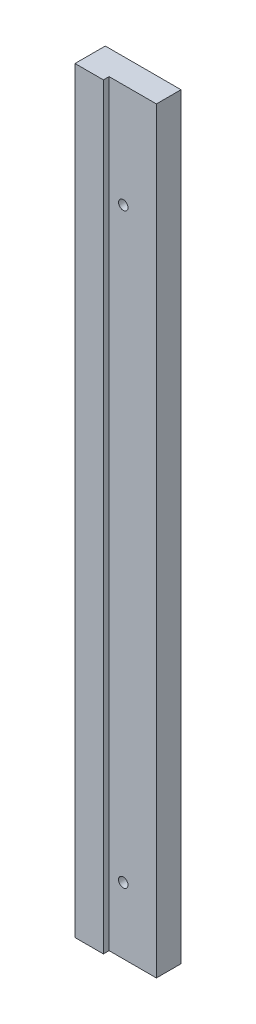
from build123d import *

# Parameters (mm, degrees)
SKETCH1_W         = 40
SKETCH1_H         = 400
EXTRUDE1_DEPTH    = 16
EXTRUDE2_REACH    = 402
SKETCH2_W         = 25
SKETCH2_H         = 3
M6_TAPPED_HOLE1_D = 5


with BuildPart() as part:
    # Sketch1 → Extrude1 (new body)
    with BuildSketch(Plane.XY):
        Rectangle(SKETCH1_W, SKETCH1_H)
    extrude(amount=EXTRUDE1_DEPTH)

    # Sketch2 → Extrude2 (cut, up to next)
    with BuildSketch(Plane.XZ.offset(200), mode=Mode.PRIVATE) as extrude2_sk1:
        with Locations((7.5, 14.5)):
            Rectangle(SKETCH2_W, SKETCH2_H)
    extrude2_tool1 = extrude(extrude2_sk1.sketch, amount=-EXTRUDE2_REACH, mode=Mode.PRIVATE) & part.part
    add(extrude2_tool1.solids().sort_by_distance((7.5, -200, 14.5))[0], mode=Mode.SUBTRACT)

    # M6 Tapped Hole1 (through all)
    with Locations(Plane(origin=(0, 0, 0), x_dir=(-1, 0, 0), z_dir=(0, 0, -1))):
        with Locations((-2.5, 145), (-2.5, -165)):
            Hole(M6_TAPPED_HOLE1_D / 2)


solid = part.part
